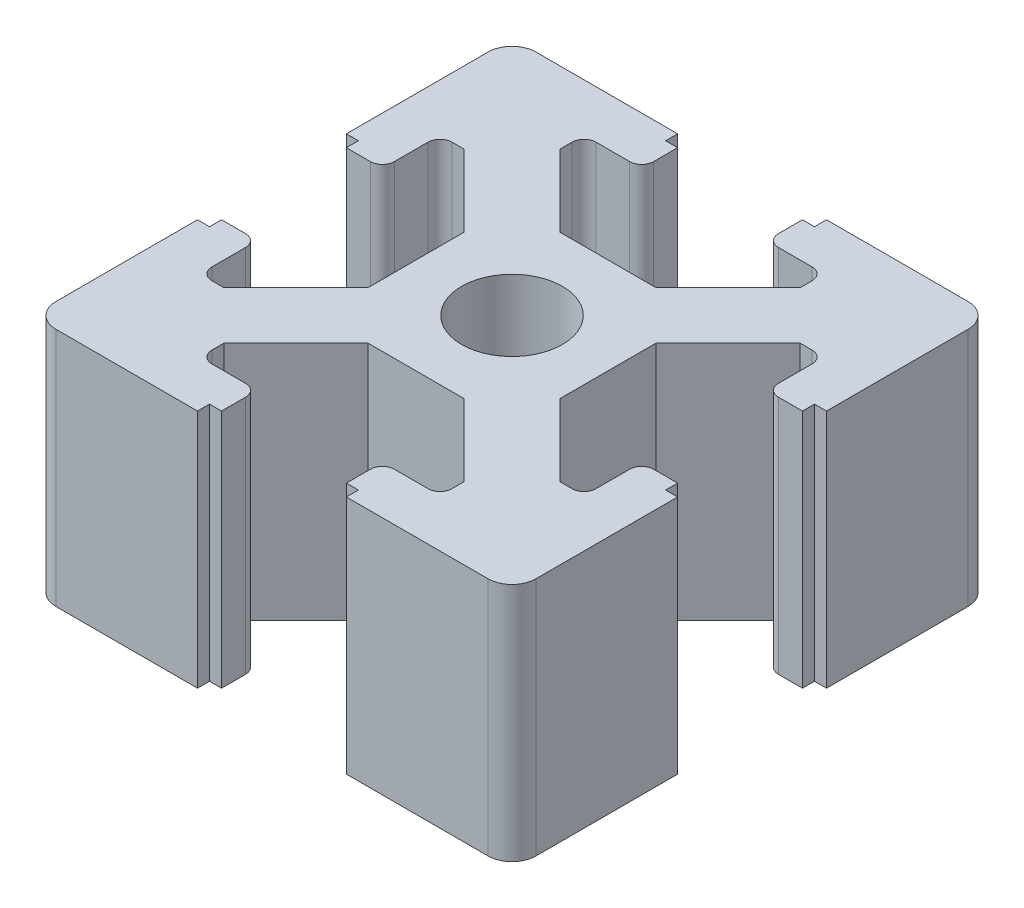
from build123d import *

# Parameters (mm, degrees)
SKETCH_1_R      = 2.1
EXTRUDE_1_DEPTH = 10


with BuildPart() as part:
    # 스케치1 → 보스-돌출1 (new body)
    with BuildSketch(Plane(origin=(0, 0, 0), x_dir=(1, 0, 0), z_dir=(0, 1, 0))):
        with BuildLine():
            Line((2, -4), (-2, -4))
            Line((-2, -4), (-5, -7))
            Line((-5, -7), (-5, -7.5))
            ThreePointArc((-5, -7.5), (-4.853553391, -7.853553391), (-4.5, -8))
            Line((-4.5, -8), (-3.1, -8))
            ThreePointArc((-3.1, -8), (-2.746446609, -8.146446609), (-2.6, -8.5))
            Line((-2.6, -8.5), (-2.6, -9.5))
            Line((-2.6, -9.5), (-3.1, -9.5))
            Line((-3.1, -9.5), (-3.1, -10))
            Line((-3.1, -10), (-9, -10))
            ThreePointArc((-9, -10), (-9.382683432, -9.923879533), (-9.707106781, -9.707106781))
            ThreePointArc((-9.707106781, -9.707106781), (-9.923879533, -9.382683432), (-10, -9))
            Line((-10, -9), (-10, -3.1))
            Line((-10, -3.1), (-9.5, -3.1))
            Line((-9.5, -3.1), (-9.5, -2.6))
            Line((-9.5, -2.6), (-8.5, -2.6))
            ThreePointArc((-8.5, -2.6), (-8.146446609, -2.746446609), (-8, -3.1))
            Line((-8, -3.1), (-8, -4.5))
            ThreePointArc((-8, -4.5), (-7.853553391, -4.853553391), (-7.5, -5))
            Line((-7.5, -5), (-7, -5))
            Line((-7, -5), (-4, -2))
            Line((-4, -2), (-4, 2))
            Line((-4, 2), (-7, 5))
            Line((-7, 5), (-7.5, 5))
            ThreePointArc((-7.5, 5), (-7.853553391, 4.853553391), (-8, 4.5))
            Line((-8, 4.5), (-8, 3.1))
            ThreePointArc((-8, 3.1), (-8.146446609, 2.746446609), (-8.5, 2.6))
            Line((-8.5, 2.6), (-9.5, 2.6))
            Line((-9.5, 2.6), (-9.5, 3.1))
            Line((-9.5, 3.1), (-10, 3.1))
            Line((-10, 3.1), (-10, 9))
            ThreePointArc((-10, 9), (-9.923879533, 9.382683432), (-9.707106781, 9.707106781))
            ThreePointArc((-9.707106781, 9.707106781), (-9.382683432, 9.923879533), (-9, 10))
            Line((-9, 10), (-3.1, 10))
            Line((-3.1, 10), (-3.1, 9.5))
            Line((-3.1, 9.5), (-2.6, 9.5))
            Line((-2.6, 9.5), (-2.6, 8.5))
            ThreePointArc((-2.6, 8.5), (-2.746446609, 8.146446609), (-3.1, 8))
            Line((-3.1, 8), (-4.5, 8))
            ThreePointArc((-4.5, 8), (-4.853553391, 7.853553391), (-5, 7.5))
            Line((-5, 7.5), (-5, 7))
            Line((-5, 7), (-2, 4))
            Line((-2, 4), (2, 4))
            Line((2, 4), (5, 7))
            Line((5, 7), (5, 7.5))
            ThreePointArc((5, 7.5), (4.853553391, 7.853553391), (4.5, 8))
            Line((4.5, 8), (3.1, 8))
            ThreePointArc((3.1, 8), (2.746446609, 8.146446609), (2.6, 8.5))
            Line((2.6, 8.5), (2.6, 9.5))
            Line((2.6, 9.5), (3.1, 9.5))
            Line((3.1, 9.5), (3.1, 10))
            Line((3.1, 10), (9, 10))
            ThreePointArc((9, 10), (9.382683432, 9.923879533), (9.707106781, 9.707106781))
            ThreePointArc((9.707106781, 9.707106781), (9.923879533, 9.382683432), (10, 9))
            Line((10, 9), (10, 3.1))
            Line((10, 3.1), (9.5, 3.1))
            Line((9.5, 3.1), (9.5, 2.6))
            Line((9.5, 2.6), (8.5, 2.6))
            ThreePointArc((8.5, 2.6), (8.146446609, 2.746446609), (8, 3.1))
            Line((8, 3.1), (8, 4.5))
            ThreePointArc((8, 4.5), (7.853553391, 4.853553391), (7.5, 5))
            Line((7.5, 5), (7, 5))
            Line((7, 5), (4, 2))
            Line((4, 2), (4, -2))
            Line((4, -2), (7, -5))
            Line((7, -5), (7.5, -5))
            ThreePointArc((7.5, -5), (7.853553391, -4.853553391), (8, -4.5))
            Line((8, -4.5), (8, -3.1))
            ThreePointArc((8, -3.1), (8.146446609, -2.746446609), (8.5, -2.6))
            Line((8.5, -2.6), (9.5, -2.6))
            Line((9.5, -2.6), (9.5, -3.1))
            Line((9.5, -3.1), (10, -3.1))
            Line((10, -3.1), (10, -9))
            ThreePointArc((10, -9), (9.923879533, -9.382683432), (9.707106781, -9.707106781))
            ThreePointArc((9.707106781, -9.707106781), (9.382683432, -9.923879533), (9, -10))
            Line((9, -10), (3.1, -10))
            Line((3.1, -10), (3.1, -9.5))
            Line((3.1, -9.5), (2.6, -9.5))
            Line((2.6, -9.5), (2.6, -8.5))
            ThreePointArc((2.6, -8.5), (2.746446609, -8.146446609), (3.1, -8))
            Line((3.1, -8), (4.5, -8))
            ThreePointArc((4.5, -8), (4.853553391, -7.853553391), (5, -7.5))
            Line((5, -7.5), (5, -7))
            Line((5, -7), (2, -4))
        make_face()
        Circle(SKETCH_1_R, mode=Mode.SUBTRACT)
    extrude(amount=EXTRUDE_1_DEPTH)


solid = part.part
